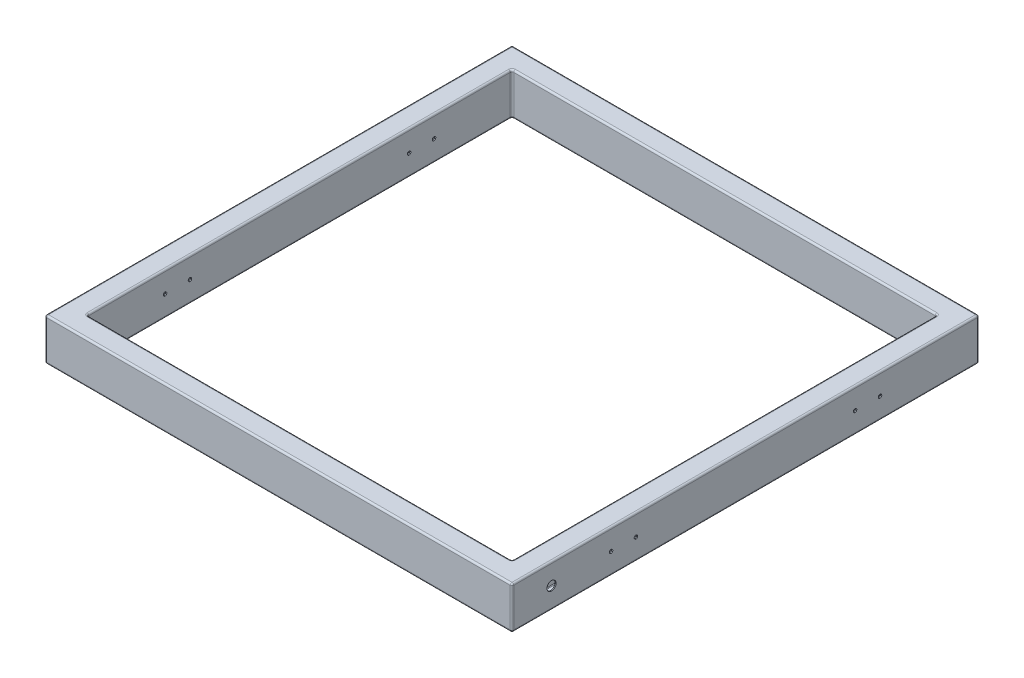
from build123d import *

# Parameters (mm, degrees)
SKETCH1_W           = 1330
SKETCH1_H           = 1330
SKETCH1_W_2         = 1210
SKETCH1_H_2         = 1210
BOSS_EXTRUDE1_DEPTH = 120
FILLET1_R           = 5
SHELL1_T            = 3
SKETCH2_R           = 5
CUT_EXTRUDE1_DEPTH  = 1331
SKETCH3_R           = 13
CUT_EXTRUDE2_DEPTH  = 60


with BuildPart() as part:
    # Sketch1 → Boss-Extrude1 (new body)
    with BuildSketch(Plane(origin=(0, 0, 0), x_dir=(1, 0, 0), z_dir=(0, 1, 0))):
        Rectangle(SKETCH1_W, SKETCH1_H)
        Rectangle(SKETCH1_W_2, SKETCH1_H_2, mode=Mode.SUBTRACT)
    extrude(amount=BOSS_EXTRUDE1_DEPTH)

    # Fillet1
    fillet1_edges = [part.edges().sort_by_distance(p)[0] for p in [
        (-665, 120, 0),
        (0, 120, 665),
        (605, 0, 0),
        (605, 60, 605),
        (0, 0, -605),
        (605, 60, -605),
        (-605, 0, 0),
        (-605, 60, -605),
        (0, 0, 605),
        (-605, 60, 605),
        (605, 120, 0),
        (0, 120, -605),
        (-605, 120, 0),
        (0, 120, 605),
        (665, 120, 0),
        (0, 0, 665),
        (-665, 0, 0),
        (0, 0, -665),
        (665, 0, 0),
        (0, 120, -665),
        (665, 60, 665),
        (-665, 60, 665),
        (-665, 60, -665),
        (665, 60, -665),
    ]]
    fillet(fillet1_edges, radius=FILLET1_R)

    # Shell1 (no face opened: a closed hollow body)
    add(offset(amount=-SHELL1_T, mode=Mode.PRIVATE), mode=Mode.SUBTRACT)

    # Sketch2 → Cut-Extrude1 (cut, through all)
    with BuildSketch(Plane.ZY.offset(665)):
        with Locations((-383, 60)):
            Circle(SKETCH2_R)
        with Locations((-312, 60)):
            Circle(SKETCH2_R)
        with Locations((383, 60)):
            Circle(SKETCH2_R)
        with Locations((312, 60)):
            Circle(SKETCH2_R)
    extrude(amount=-CUT_EXTRUDE1_DEPTH, mode=Mode.SUBTRACT)

    # Sketch3 → Cut-Extrude2 (cut)
    with BuildSketch(Plane(origin=(665, 0, 0), x_dir=(0, 0, -1), z_dir=(1, 0, 0))):
        with Locations((-552.5, 60)):
            Circle(SKETCH3_R)
    extrude(amount=-CUT_EXTRUDE2_DEPTH, mode=Mode.SUBTRACT)


solid = part.part
